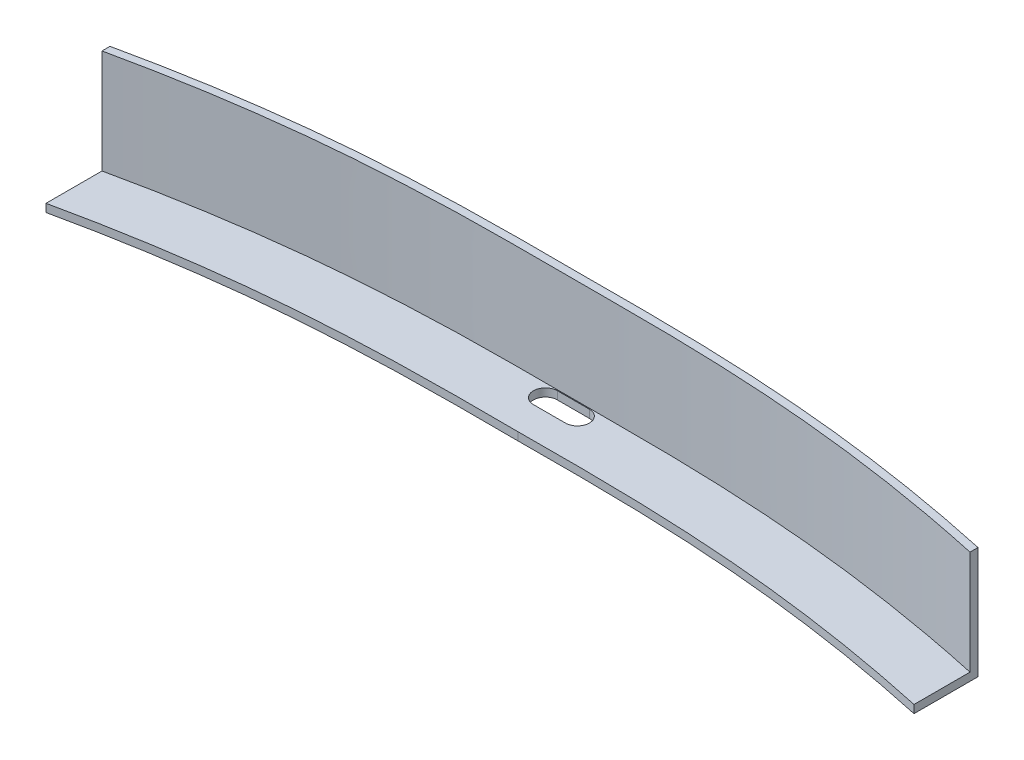
from build123d import *

# Parameters (mm, degrees)
BOSS_EXTRUDE1_DEPTH     = 14
CUT_EXTRUDE1_DEPTH      = 13
CUT_EXTRUDE4_DEPTH      = 8
CUT_EXTRUDE4_DEPTH_BACK = 10


with BuildPart() as part:
    # Sketch1 → Boss-Extrude1 (new body)
    with BuildSketch(Plane(origin=(0, 0, 0), x_dir=(1, 0, 0), z_dir=(0, 1, 0))):
        with BuildLine():
            Line((-56.7108806, 8.042770274), (-56.7108806, 6.805307476))
            Line((-56.7108806, 6.805307476), (-32.823491302, 6.805307476))
            add(Edge.make_bspline(
                [(-32.823491302, 6.805307476), (-32.296255898, 6.856181615), (-26.989208291, 7.346453988), (-16.87934757, 7.860332352), (-7.605819721, 7.844934175), (-2.44151388, 7.817702683)],
                knots=[0.442922252, 0.442922252, 0.442922252, 0.442922252, 0.47203113, 0.735860593, 1, 1, 1, 1], degree=3))
            add(Edge.make_bspline(
                [(27.940463543, 6.805307476), (27.413228139, 6.856181615), (22.106180532, 7.346453988), (11.99631981, 7.860332352), (2.722791962, 7.844934175), (-2.44151388, 7.817702683)],
                knots=[0.442922252, 0.442922252, 0.442922252, 0.442922252, 0.47203113, 0.735860593, 1, 1, 1, 1], degree=3))
            Line((27.940463543, 6.805307476), (51.827852841, 6.805307476))
            Line((51.827852841, 6.805307476), (51.827852841, 8.042770274))
            add(Edge.make_bspline(
                [(51.827852841, 8.042770274), (43.440678216, 9.870534091), (30.144344491, 11.93787877), (11.99631981, 12.860332352), (2.722791962, 12.844934175), (-2.44151388, 12.817702683)],
                knots=[0, 0, 0, 0, 0.47203113, 0.735860593, 1, 1, 1, 1], degree=3))
            add(Edge.make_bspline(
                [(-56.7108806, 8.042770274), (-48.323705975, 9.870534091), (-35.02737225, 11.93787877), (-16.87934757, 12.860332352), (-7.605819721, 12.844934175), (-2.44151388, 12.817702683)],
                knots=[0, 0, 0, 0, 0.47203113, 0.735860593, 1, 1, 1, 1], degree=3))
        make_face()
        with BuildLine():
            Line((-32.823491302, 6.805307476), (-56.7108806, 6.805307476))
            Line((-56.7108806, 6.805307476), (-56.7108806, 3.042770274))
            add(Edge.make_bspline(
                [(-56.7108806, 3.042770274), (-48.840920262, 4.757820859), (-40.845933501, 6.031203848), (-32.823491302, 6.805307476)],
                knots=[0, 0, 0, 0, 0.442922252, 0.442922252, 0.442922252, 0.442922252], degree=3))
        make_face()
        with BuildLine():
            add(Edge.make_bspline(
                [(-32.823491302, 6.805307476), (-32.296255898, 6.856181615), (-26.989208291, 7.346453988), (-16.87934757, 7.860332352), (-7.605819721, 7.844934175), (-2.44151388, 7.817702683)],
                knots=[0.442922252, 0.442922252, 0.442922252, 0.442922252, 0.47203113, 0.735860593, 1, 1, 1, 1], degree=3))
            Line((-32.823491302, 6.805307476), (-13.104631083, 6.805307476))
            add(Edge.make_bspline(
                [(-13.104631083, 6.805307476), (-9.673457151, 6.846977378), (-6.196193741, 6.837501188), (-2.44151388, 6.817702683)],
                knots=[0.807958912, 0.807958912, 0.807958912, 0.807958912, 1, 1, 1, 1], degree=3))
            add(Edge.make_bspline(
                [(8.221603324, 6.805307476), (4.790429392, 6.846977378), (1.313165982, 6.837501188), (-2.44151388, 6.817702683)],
                knots=[0.807958912, 0.807958912, 0.807958912, 0.807958912, 1, 1, 1, 1], degree=3))
            Line((8.221603324, 6.805307476), (27.940463543, 6.805307476))
            add(Edge.make_bspline(
                [(27.940463543, 6.805307476), (27.413228139, 6.856181615), (22.106180532, 7.346453988), (11.99631981, 7.860332352), (2.722791962, 7.844934175), (-2.44151388, 7.817702683)],
                knots=[0.442922252, 0.442922252, 0.442922252, 0.442922252, 0.47203113, 0.735860593, 1, 1, 1, 1], degree=3))
        make_face()
        with BuildLine():
            Line((-13.104631083, 6.805307476), (-32.823491302, 6.805307476))
            add(Edge.make_bspline(
                [(-56.7108806, 3.042770274), (-48.840920262, 4.757820859), (-40.845933501, 6.031203848), (-32.823491302, 6.805307476)],
                knots=[0, 0, 0, 0, 0.442922252, 0.442922252, 0.442922252, 0.442922252], degree=3))
            Line((-56.7108806, 3.042770274), (-56.7108806, 2.042770274))
            add(Edge.make_bspline(
                [(-56.7108806, 2.042770274), (-48.323705975, 3.870534091), (-35.02737225, 5.93787877), (-20.364513976, 6.683183362), (-14.392802669, 6.789663273), (-13.104631083, 6.805307476)],
                knots=[0, 0, 0, 0, 0.47203113, 0.735860593, 0.807958912, 0.807958912, 0.807958912, 0.807958912], degree=3))
        make_face()
        with BuildLine():
            Line((-56.7108806, 10.042770274), (-56.7108806, 8.042770274))
            add(Edge.make_bspline(
                [(-56.7108806, 8.042770274), (-48.323705975, 9.870534091), (-35.02737225, 11.93787877), (-16.87934757, 12.860332352), (-7.605819721, 12.844934175), (-2.44151388, 12.817702683)],
                knots=[0, 0, 0, 0, 0.47203113, 0.735860593, 1, 1, 1, 1], degree=3))
            add(Edge.make_bspline(
                [(51.827852841, 8.042770274), (43.440678216, 9.870534091), (30.144344491, 11.93787877), (11.99631981, 12.860332352), (2.722791962, 12.844934175), (-2.44151388, 12.817702683)],
                knots=[0, 0, 0, 0, 0.47203113, 0.735860593, 1, 1, 1, 1], degree=3))
            Line((51.827852841, 8.042770274), (51.827852841, 10.042770274))
            add(Edge.make_bspline(
                [(51.827852841, 10.042770274), (43.440678216, 11.870534091), (30.144344491, 13.93787877), (11.99631981, 14.860332352), (2.722791962, 14.844934175), (-2.44151388, 14.817702683)],
                knots=[0, 0, 0, 0, 0.47203113, 0.735860593, 1, 1, 1, 1], degree=3))
            add(Edge.make_bspline(
                [(-56.7108806, 10.042770274), (-48.323705975, 11.870534091), (-35.02737225, 13.93787877), (-16.87934757, 14.860332352), (-7.605819721, 14.844934175), (-2.44151388, 14.817702683)],
                knots=[0, 0, 0, 0, 0.47203113, 0.735860593, 1, 1, 1, 1], degree=3))
        make_face()
        with BuildLine():
            Line((27.940463543, 6.805307476), (8.221603324, 6.805307476))
            add(Edge.make_bspline(
                [(51.827852841, 2.042770274), (43.440678216, 3.870534091), (30.144344491, 5.93787877), (15.481486217, 6.683183362), (9.50977491, 6.789663273), (8.221603324, 6.805307476)],
                knots=[0, 0, 0, 0, 0.47203113, 0.735860593, 0.807958912, 0.807958912, 0.807958912, 0.807958912], degree=3))
            Line((51.827852841, 2.042770274), (51.827852841, 3.042770274))
            add(Edge.make_bspline(
                [(51.827852841, 3.042770274), (43.957892503, 4.757820859), (35.962905742, 6.031203848), (27.940463543, 6.805307476)],
                knots=[0, 0, 0, 0, 0.442922252, 0.442922252, 0.442922252, 0.442922252], degree=3))
        make_face()
        with BuildLine():
            Line((51.827852841, 6.805307476), (27.940463543, 6.805307476))
            add(Edge.make_bspline(
                [(51.827852841, 3.042770274), (43.957892503, 4.757820859), (35.962905742, 6.031203848), (27.940463543, 6.805307476)],
                knots=[0, 0, 0, 0, 0.442922252, 0.442922252, 0.442922252, 0.442922252], degree=3))
            Line((51.827852841, 3.042770274), (51.827852841, 6.805307476))
        make_face()
    extrude(amount=BOSS_EXTRUDE1_DEPTH)

    # Sketch2 → Cut-Extrude1 (cut)
    with BuildSketch(Plane(origin=(0, 14, 0), x_dir=(1, 0, 0), z_dir=(0, 1, 0))):
        with BuildLine():
            Line((-56.7108806, 2.042770274), (-56.7108806, 5.542770274))
            Line((-56.7108806, 5.542770274), (-56.7108806, 9.042770274))
            Line((-56.7108806, 9.042770274), (-60.802173019, 3.895333481))
            Line((-60.802173019, 3.895333481), (-51.218147628, -5.393798822))
            Line((-51.218147628, -5.393798822), (49.094651471, -7.261455052))
            Line((49.094651471, -7.261455052), (58.165802049, 3.042770274))
            Line((58.165802049, 3.042770274), (51.827852841, 9.042770274))
            Line((51.827852841, 9.042770274), (51.827852841, 5.542770274))
            Line((51.827852841, 5.542770274), (51.827852841, 2.042770274))
            add(Edge.make_bspline(
                [(51.827852841, 2.042770274), (43.440678216, 3.870534091), (30.144344491, 5.93787877), (15.481486217, 6.683183362), (9.50977491, 6.789663273), (8.221603324, 6.805307476)],
                knots=[0, 0, 0, 0, 0.47203113, 0.735860593, 0.807958912, 0.807958912, 0.807958912, 0.807958912], degree=3))
            add(Edge.make_bspline(
                [(8.221603324, 6.805307476), (4.790429392, 6.846977378), (1.313165982, 6.837501188), (-2.44151388, 6.817702683)],
                knots=[0.807958912, 0.807958912, 0.807958912, 0.807958912, 1, 1, 1, 1], degree=3))
            add(Edge.make_bspline(
                [(-13.104631083, 6.805307476), (-9.673457151, 6.846977378), (-6.196193741, 6.837501188), (-2.44151388, 6.817702683)],
                knots=[0.807958912, 0.807958912, 0.807958912, 0.807958912, 1, 1, 1, 1], degree=3))
            add(Edge.make_bspline(
                [(-56.7108806, 2.042770274), (-48.323705975, 3.870534091), (-35.02737225, 5.93787877), (-20.364513976, 6.683183362), (-14.392802669, 6.789663273), (-13.104631083, 6.805307476)],
                knots=[0, 0, 0, 0, 0.47203113, 0.735860593, 0.807958912, 0.807958912, 0.807958912, 0.807958912], degree=3))
        make_face()
        with BuildLine():
            add(Edge.make_bspline(
                [(-54.7108806, 5.968393843), (-49.670914824, 7.015705417), (-41.543596045, 8.398869396), (-30.478251076, 9.58618105), (-21.960755969, 10.106039162), (-12.680255084, 10.366102662), (-2.488255396, 10.288816201), (7.839601208, 10.366738732), (17.143204354, 10.104590131), (25.594666904, 9.581695492), (36.57167706, 8.41148596), (44.677902085, 7.038580739), (49.827852841, 5.968402081)],
                knots=[0.018721822, 0.018721822, 0.018721822, 0.018721822, 0.160113822, 0.245011966, 0.32430349, 0.394459254, 0.499999871, 0.60425614, 0.678146052, 0.755618705, 0.836798939, 0.981277891, 0.981277891, 0.981277891, 0.981277891], degree=3))
            add(Edge.make_bspline(
                [(-56.7108806, 5.542770274), (-56.044902341, 5.687833423), (-55.378226304, 5.82971852), (-54.7108806, 5.968393843)],
                knots=[0, 0, 0, 0, 0.018721822, 0.018721822, 0.018721822, 0.018721822], degree=3))
            Line((-56.7108806, 5.542770274), (-56.7108806, 2.042770274))
            add(Edge.make_bspline(
                [(-56.7108806, 2.042770274), (-48.323705975, 3.870534091), (-35.02737225, 5.93787877), (-20.364513976, 6.683183362), (-14.392802669, 6.789663273), (-13.104631083, 6.805307476)],
                knots=[0, 0, 0, 0, 0.47203113, 0.735860593, 0.807958912, 0.807958912, 0.807958912, 0.807958912], degree=3))
            add(Edge.make_bspline(
                [(-13.104631083, 6.805307476), (-9.673457151, 6.846977378), (-6.196193741, 6.837501188), (-2.44151388, 6.817702683)],
                knots=[0.807958912, 0.807958912, 0.807958912, 0.807958912, 1, 1, 1, 1], degree=3))
            add(Edge.make_bspline(
                [(8.221603324, 6.805307476), (4.790429392, 6.846977378), (1.313165982, 6.837501188), (-2.44151388, 6.817702683)],
                knots=[0.807958912, 0.807958912, 0.807958912, 0.807958912, 1, 1, 1, 1], degree=3))
            add(Edge.make_bspline(
                [(51.827852841, 2.042770274), (43.440678216, 3.870534091), (30.144344491, 5.93787877), (15.481486217, 6.683183362), (9.50977491, 6.789663273), (8.221603324, 6.805307476)],
                knots=[0, 0, 0, 0, 0.47203113, 0.735860593, 0.807958912, 0.807958912, 0.807958912, 0.807958912], degree=3))
            Line((51.827852841, 2.042770274), (51.827852841, 5.542770274))
            add(Edge.make_bspline(
                [(49.827852841, 5.968402081), (50.495202231, 5.82972443), (51.161878542, 5.687836633), (51.827852841, 5.542770274)],
                knots=[0.981277891, 0.981277891, 0.981277891, 0.981277891, 1, 1, 1, 1], degree=3))
        make_face()
        with BuildLine():
            Line((-54.7108806, 9.468393843), (-54.7108806, 5.968393843))
            add(Edge.make_bspline(
                [(-54.7108806, 5.968393843), (-49.670914824, 7.015705417), (-41.543596045, 8.398869396), (-30.478251076, 9.58618105), (-21.960755969, 10.106039162), (-12.680255084, 10.366102662), (-2.488255396, 10.288816201), (7.839601208, 10.366738732), (17.143204354, 10.104590131), (25.594666904, 9.581695492), (36.57167706, 8.41148596), (44.677902085, 7.038580739), (49.827852841, 5.968402081)],
                knots=[0.018721822, 0.018721822, 0.018721822, 0.018721822, 0.160113822, 0.245011966, 0.32430349, 0.394459254, 0.499999871, 0.60425614, 0.678146052, 0.755618705, 0.836798939, 0.981277891, 0.981277891, 0.981277891, 0.981277891], degree=3))
            Line((49.827852841, 5.968402081), (49.827852841, 9.468402081))
            add(Edge.make_bspline(
                [(-54.7108806, 9.468393843), (-49.670914824, 10.515705417), (-41.543596045, 11.898869396), (-30.478251076, 13.08618105), (-21.960755969, 13.606039162), (-12.680255084, 13.866102662), (-2.488255396, 13.788816201), (7.839601208, 13.866738732), (17.143204354, 13.604590131), (25.594666904, 13.081695492), (36.57167706, 11.91148596), (44.677902085, 10.538580739), (49.827852841, 9.468402081)],
                knots=[0.018721822, 0.018721822, 0.018721822, 0.018721822, 0.160113822, 0.245011966, 0.32430349, 0.394459254, 0.499999871, 0.60425614, 0.678146052, 0.755618705, 0.836798939, 0.981277891, 0.981277891, 0.981277891, 0.981277891], degree=3))
        make_face()
        with BuildLine():
            add(Edge.make_bspline(
                [(-56.7108806, 5.542770274), (-56.044902341, 5.687833423), (-55.378226304, 5.82971852), (-54.7108806, 5.968393843)],
                knots=[0, 0, 0, 0, 0.018721822, 0.018721822, 0.018721822, 0.018721822], degree=3))
            Line((-54.7108806, 5.968393843), (-54.7108806, 9.468393843))
            add(Edge.make_bspline(
                [(-56.7108806, 9.042770274), (-56.044902341, 9.187833423), (-55.378226304, 9.32971852), (-54.7108806, 9.468393843)],
                knots=[0, 0, 0, 0, 0.018721822, 0.018721822, 0.018721822, 0.018721822], degree=3))
            Line((-56.7108806, 9.042770274), (-56.7108806, 5.542770274))
        make_face()
        with BuildLine():
            Line((49.827852841, 9.468402081), (49.827852841, 5.968402081))
            add(Edge.make_bspline(
                [(49.827852841, 5.968402081), (50.495202231, 5.82972443), (51.161878542, 5.687836633), (51.827852841, 5.542770274)],
                knots=[0.981277891, 0.981277891, 0.981277891, 0.981277891, 1, 1, 1, 1], degree=3))
            Line((51.827852841, 5.542770274), (51.827852841, 9.042770274))
            add(Edge.make_bspline(
                [(49.827852841, 9.468402081), (50.495202231, 9.32972443), (51.161878542, 9.187836633), (51.827852841, 9.042770274)],
                knots=[0.981277891, 0.981277891, 0.981277891, 0.981277891, 1, 1, 1, 1], degree=3))
        make_face()
    extrude(amount=-CUT_EXTRUDE1_DEPTH, mode=Mode.SUBTRACT)

    # Sketch7 → Cut-Extrude4 (cut, two sides)
    with BuildSketch(Plane(origin=(0, 1, 0), x_dir=(1, 0, 0), z_dir=(0, 1, 0))) as cut_extrude4_sk:
        with BuildLine():
            Line((-4.44151388, 13.717702683), (-0.44151388, 13.717702683))
            ThreePointArc((-0.44151388, 13.717702683), (1.05848612, 12.217702683), (-0.44151388, 10.717702683))
            Line((-0.44151388, 10.717702683), (-4.44151388, 10.717702683))
            ThreePointArc((-4.44151388, 10.717702683), (-5.94151388, 12.217702683), (-4.44151388, 13.717702683))
        make_face()
    extrude(amount=CUT_EXTRUDE4_DEPTH, mode=Mode.SUBTRACT)
    extrude(cut_extrude4_sk.sketch, amount=-CUT_EXTRUDE4_DEPTH_BACK, mode=Mode.SUBTRACT)


solid = part.part
